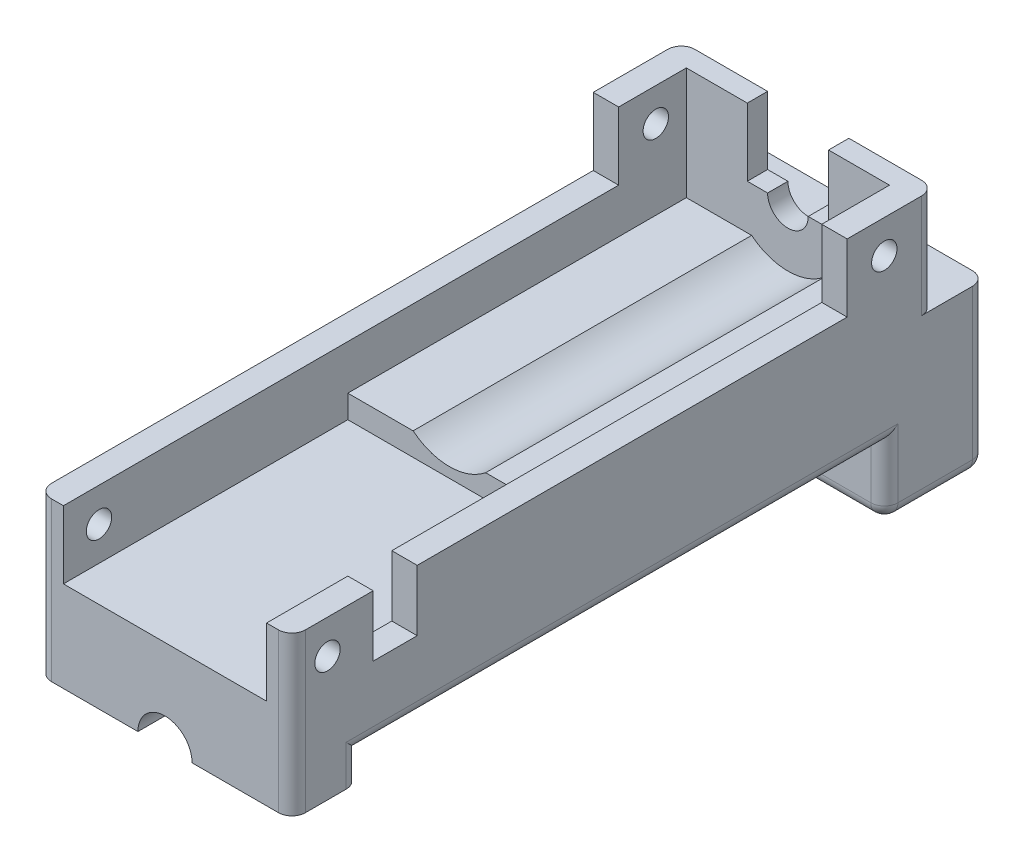
from build123d import *

# Parameters (mm, degrees)
SKETCH2_W                 = 37.5
SKETCH2_H                 = 95
BOSS_EXTRUDE1_DEPTH       = 15
SKETCH3_W                 = 30
SKETCH3_H                 = 42
CUT_EXTRUDE1_DEPTH        = 10
SKETCH5_R                 = 8.5
SKETCH5_W                 = 30
SKETCH5_H                 = 6.6
CUT_EXTRUDE2_DEPTH        = 50
CUT_EXTRUDE3_DEPTH        = 10
SKETCH7_W                 = 6.5
SKETCH7_H                 = 9
CUT_EXTRUDE4_DEPTH        = 3.75
SKETCH8_W                 = 12.75
SKETCH8_H                 = 3
BOSS_EXTRUDE2_DEPTH       = 10
F_2_5MM_DOWEL_HOLE2_D     = 3.75
SKETCH14_W                = 37.5
SKETCH14_H                = 15
BOSS_EXTRUDE3_DEPTH       = 14.5
CUT_EXTRUDE5_DEPTH        = 11.1125
SKETCH16_W                = 8.89
SKETCH16_H                = 8.8125
BOSS_EXTRUDE4_DEPTH       = 1
SKETCH17_W                = 3.75
SKETCH17_H                = 10
BOSS_EXTRUDE5_DEPTH       = 10
F_2_5MM_DOWEL_HOLE3_D     = 3.75
SKETCH24_W                = 37.5
SKETCH24_H                = 4.3875
BOSS_EXTRUDE7_DEPTH       = 87.5
BOSS_EXTRUDE8_DEPTH       = 10
SKETCH26_W                = 37.5
SKETCH26_H                = 9.690281336
BOSS_EXTRUDE9_DEPTH       = 7.5
SKETCH27_W                = 20.05
SKETCH27_H                = 6.4
CUT_EXTRUDE6_DEPTH        = 14.6
FILLET2_R                 = 2
F_2_5MM_DOWEL_HOLE4_D     = 5.5
F_2_5MM_DOWEL_HOLE4_DEPTH = 5
F_2_5MM_DOWEL_HOLE4_TIP   = 1.652366702
SKETCH31_W                = 4.284862737
SKETCH31_H                = 6.4
CUT_EXTRUDE7_DEPTH        = 112.002252229
CUT_EXTRUDE8_DEPTH        = 1.5


with BuildPart() as part:
    # Sketch2 → Boss-Extrude1 (new body)
    with BuildSketch(Plane(origin=(0, 0, 0), x_dir=(1, 0, 0), z_dir=(0, 1, 0))):
        with Locations((18.75, 47.5)):
            Rectangle(SKETCH2_W, SKETCH2_H)
    extrude(amount=BOSS_EXTRUDE1_DEPTH)

    # Sketch3 → Cut-Extrude1 (cut)
    with BuildSketch(Plane(origin=(0, 15, 0), x_dir=(1, 0, 0), z_dir=(0, 1, 0))):
        with Locations((18.75, 21)):
            Rectangle(SKETCH3_W, SKETCH3_H)
    extrude(amount=-CUT_EXTRUDE1_DEPTH, mode=Mode.SUBTRACT)

    # Sketch5 → Cut-Extrude2 (cut)
    with BuildSketch(Plane.XY.offset(-42)):
        with Locations((18.75, 15)):
            Circle(SKETCH5_R)
        with Locations((18.75, 11.7)):
            Rectangle(SKETCH5_W, SKETCH5_H)
    extrude(amount=-CUT_EXTRUDE2_DEPTH, mode=Mode.SUBTRACT)

    # Sketch6 → Cut-Extrude3 (cut)
    with BuildSketch(Plane(origin=(0, 0, -95), x_dir=(-1, 0, 0), z_dir=(0, 0, -1))):
        with BuildLine():
            Line((-21.75, 15), (-15.75, 15))
            ThreePointArc((-15.75, 15), (-18.75, 12), (-21.75, 15))
        make_face()
    extrude(amount=-CUT_EXTRUDE3_DEPTH, mode=Mode.SUBTRACT)

    # Sketch7 → Cut-Extrude4 (cut)
    with BuildSketch(Plane.ZY.offset(-37.5)):
        with Locations((-15.25, 10.5)):
            Rectangle(SKETCH7_W, SKETCH7_H)
    extrude(amount=CUT_EXTRUDE4_DEPTH, mode=Mode.SUBTRACT)

    # Sketch8 → Boss-Extrude2 (add)
    with BuildSketch(Plane(origin=(0, 15, 0), x_dir=(1, 0, 0), z_dir=(0, 1, 0))):
        with Locations((6.375, 93.5)):
            Rectangle(SKETCH8_W, SKETCH8_H)
    boss_extrude2 = extrude(amount=BOSS_EXTRUDE2_DEPTH)

    # Mirror1: Boss-Extrude2 across plane
    add(boss_extrude2.mirror(Plane.ZY.offset(-18.75)))

    # Ø2.5mm Dowel Hole2 (through all)
    with Locations(Plane(origin=(37.5, 0, 0), x_dir=(0, 0, -1), z_dir=(1, 0, 0))):
        with Locations((5.25, 10)):
            Hole(F_2_5MM_DOWEL_HOLE2_D / 2)

    # Sketch14 → Boss-Extrude3 (add)
    with BuildSketch(Plane.XZ):
        with Locations((18.75, -95)):
            Rectangle(SKETCH14_W, SKETCH14_H)
    extrude(amount=BOSS_EXTRUDE3_DEPTH)

    # Sketch15 → Cut-Extrude5 (cut)
    with BuildSketch(Plane.XZ.offset(14.5)):
        Polygon((16.143541, -102.5), (16.143541, -100), (12.003125, -100), (12.003125, -96.3125), (14.305, -96.3125), (14.305, -87.5), (23.195, -87.5), (23.195, -96.3125), (25.496875, -96.3125), (25.496875, -100), (21.356459, -100), (21.356459, -102.5), align=None)
    extrude(amount=-CUT_EXTRUDE5_DEPTH, mode=Mode.SUBTRACT)

    # Sketch16 → Boss-Extrude4 (add)
    with BuildSketch(Plane.XZ.offset(3.3875)):
        with Locations((18.75, -91.90625)):
            Rectangle(SKETCH16_W, SKETCH16_H)
    extrude(amount=BOSS_EXTRUDE4_DEPTH)

    # Sketch17 → Boss-Extrude5 (add)
    with BuildSketch(Plane(origin=(0, 15, 0), x_dir=(1, 0, 0), z_dir=(0, 1, 0))):
        with Locations((1.875, 87)):
            Rectangle(SKETCH17_W, SKETCH17_H)
        with Locations((35.625, 87)):
            Rectangle(SKETCH17_W, SKETCH17_H)
    extrude(amount=BOSS_EXTRUDE5_DEPTH)

    # Ø2.5mm Dowel Hole3 (through all)
    with Locations(Plane(origin=(37.5, 0, 0), x_dir=(0, 0, -1), z_dir=(1, 0, 0))):
        with Locations((87.486504599, 20.104293775)):
            Hole(F_2_5MM_DOWEL_HOLE3_D / 2)

    # Sketch24 → Boss-Extrude7 (add)
    with BuildSketch(Plane.XY.offset(-87.5)):
        with Locations((18.75, -2.19375)):
            Rectangle(SKETCH24_W, SKETCH24_H)
    extrude(amount=BOSS_EXTRUDE7_DEPTH)

    # Sketch25 → Boss-Extrude8 (add)
    with BuildSketch(Plane.XY):
        with BuildLine():
            Line((37.5, -4.3875), (18.75, -4.3875))
            ThreePointArc((18.75, -4.3875), (21.578427125, -5.559072875), (22.75, -8.3875))
            Line((22.75, -8.3875), (37.5, -8.3875))
            Line((37.5, -8.3875), (37.5, -4.3875))
        make_face()
        with BuildLine():
            Line((18.75, -4.3875), (0, -4.3875))
            Line((0, -4.3875), (0, -8.3875))
            Line((0, -8.3875), (14.75, -8.3875))
            ThreePointArc((14.75, -8.3875), (15.921572875, -5.559072875), (18.75, -4.3875))
        make_face()
    extrude(amount=-BOSS_EXTRUDE8_DEPTH)

    # Sketch26 → Boss-Extrude9 (add)
    with BuildSketch(Plane(origin=(0, 0, -95), x_dir=(-1, 0, 0), z_dir=(0, 0, -1))):
        with Locations((-18.75, 4.845140668)):
            Rectangle(SKETCH26_W, SKETCH26_H)
    extrude(amount=BOSS_EXTRUDE9_DEPTH)

    # Sketch27 → Cut-Extrude6 (cut)
    with BuildSketch(Plane(origin=(0, 0, -102.5), x_dir=(-1, 0, 0), z_dir=(0, 0, -1))):
        with Locations((-13.025, 2.990281336)):
            Rectangle(SKETCH27_W, SKETCH27_H)
    extrude(amount=-CUT_EXTRUDE6_DEPTH, mode=Mode.SUBTRACT)

    # Fillet2
    fillet2_edges = [part.edges().sort_by_distance(p)[0] for p in [
        (0, -9.44375, -87.5),
        (0, -2.404859332, -102.5),
        (37.5, -2.404859332, -102.5),
        (37.5, -9.44375, -87.5),
        (0, -14.5, -95),
        (8.0717705, -14.5, -102.5),
        (37.5, -14.5, -95),
        (30.3475, -14.5, -87.5),
        (29.4282295, -14.5, -102.5),
        (7.1525, -14.5, -87.5),
        (37.5, -4.3875, -48.75),
        (37.5, -6.3875, -10),
        (0, -4.3875, -48.75),
        (0, -6.3875, -10),
        (0, 17.345140668, -95),
        (37.5, 17.345140668, -95),
        (37.5, 3.30625, 0),
        (0, 3.30625, 0),
    ]]
    fillet(fillet2_edges, radius=FILLET2_R)

    # Ø2.5mm Dowel Hole4
    with Locations(Plane(origin=(0, -8.3875, 0), x_dir=(-1, 0, 0), z_dir=(0, -1, 0))):
        with Locations((-32.5, 5), (-5, 5)):
            Hole(F_2_5MM_DOWEL_HOLE4_D / 2, depth=F_2_5MM_DOWEL_HOLE4_DEPTH)
            with Locations((0, 0, -(F_2_5MM_DOWEL_HOLE4_DEPTH + F_2_5MM_DOWEL_HOLE4_TIP / 2))):  # 118° drill point
                Cone(0, F_2_5MM_DOWEL_HOLE4_D / 2, F_2_5MM_DOWEL_HOLE4_TIP, mode=Mode.SUBTRACT)

    # Sketch31 → Cut-Extrude7 (cut, through all)
    with BuildSketch(Plane(origin=(3, 0, 0), x_dir=(0, 0, -1), z_dir=(1, 0, 0))):
        with Locations((90.042431369, 2.990281336)):
            Rectangle(SKETCH31_W, SKETCH31_H)
    extrude(amount=-CUT_EXTRUDE7_DEPTH, mode=Mode.SUBTRACT)

    # Sketch32 → Cut-Extrude8 (cut)
    with BuildSketch(Plane.XZ.offset(4.3875)):
        Polygon((32.662211036, -66.731402862), (32.662211036, -60.842760163), (31.314060446, -61.257991767), (31.314060446, -51.061409973), (31.181038698, -49.082813371), (30.740043615, -47.651015368), (30.272932489, -46.702611031), (29.343491661, -45.825186496), (28.166570354, -45.289551545), (26.913013893, -45.172232341), (25.487931235, -45.415918592), (23.663222713, -46.115147592), (22.123128119, -47.024353691), (21.210078183, -47.821011367), (20.018893116, -49.082813371), (18.887507594, -51.061409973), (18.257769049, -52.911736478), (17.912229988, -55.231688956), (19.282356905, -54.7066558), (19.282356905, -61.531664738), (17.863237505, -62.075471832), (17.863237505, -66.360306951), (16.408711909, -66.917681713), (16.408711909, -72.685258984), (23.193470428, -70.305264788), (23.193470428, -54.347624256), (23.331002369, -53.424233522), (23.59042172, -52.661995758), (24.115625328, -52.105656542), (24.950101738, -51.812934405), (25.728287005, -52.077781315), (25.967613662, -52.760040784), (25.967613662, -69.19073609), align=None)
        Polygon((18.887507594, -61.257991767), (18.887507594, -55.376949047), (17.389382, -55.927301794), (17.389382, -43.806150983), (18.887507594, -43.255798236), (18.887507594, -37.448382085), (13.405832614, -39.371273607), (11.177740444, -40.341723555), (10.100640592, -40.98328383), (8.936720005, -41.849530032), (7.790955921, -42.951413953), (6.783486907, -44.128073894), (6.081538262, -45.289551545), (5.270405037, -47.097284534), (4.808853701, -48.478793464), (4.295716054, -50.413974213), (4.021830569, -53.238519595), (4.021830569, -56.833755888), (4.295716054, -58.862358442), (4.808853701, -60.527748098), (5.381572286, -61.842674021), (6.348688627, -62.848303696), (7.790955921, -63.886150712), (9.142953346, -64.244649926), (10.639190518, -64.244649926), (11.974170787, -63.886150712), align=None)
        Polygon((12.135932336, -57.848057165), (12.135932336, -45.679668485), (11.306680653, -46.296837843), (10.540601176, -47.191570107), (9.999416807, -48.284787608), (9.642235274, -49.631815705), (9.392627445, -51.131802286), (9.330267236, -52.833612335), (9.392627445, -54.227691449), (9.569214099, -55.535625441), (9.82082604, -56.47257862), (10.338657712, -57.470582903), (10.923640914, -57.97145187), (11.554307118, -57.97145187), align=None, mode=Mode.SUBTRACT)
    extrude(amount=-CUT_EXTRUDE8_DEPTH, mode=Mode.SUBTRACT)


solid = part.part
